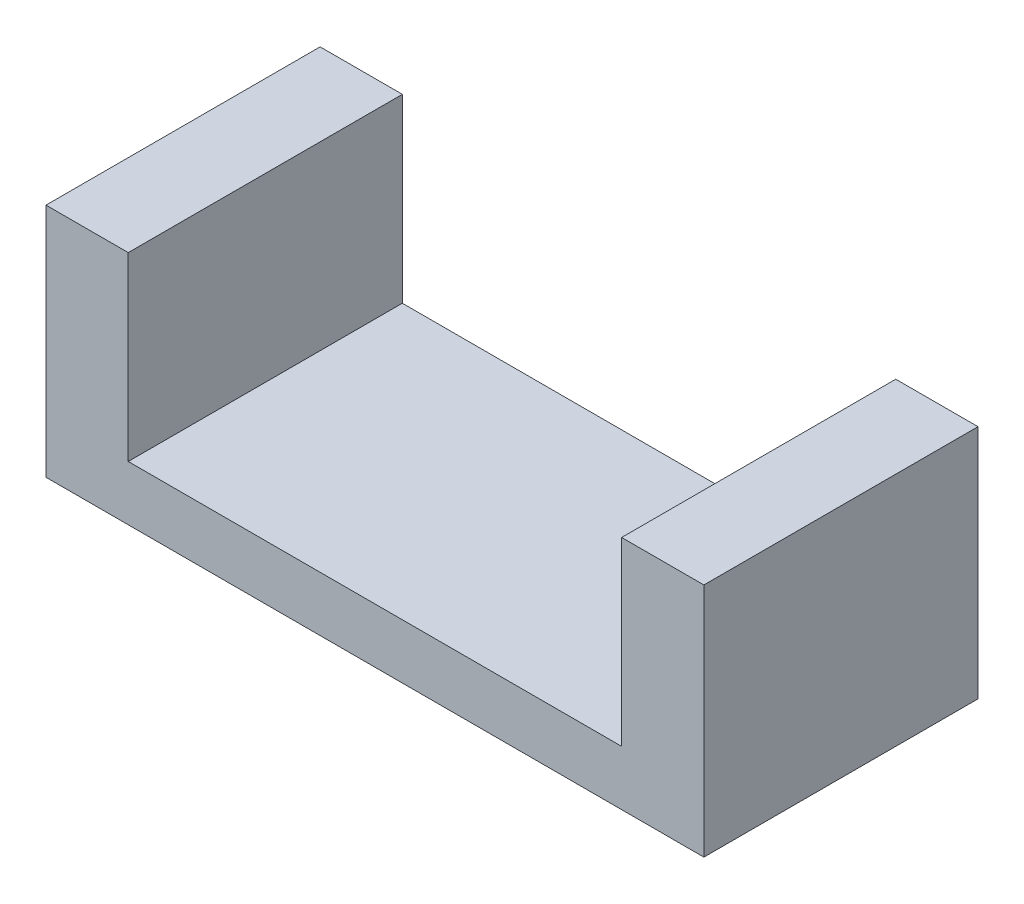
from build123d import *

# Parameters (mm, degrees)
SKETCH_1_W      = 9
SKETCH_1_H      = 5
EXTRUDE_1_DEPTH = 1
SKETCH_1_3_W    = 1.5
SKETCH_1_3_H    = 5
EXTRUDE_2_DEPTH = 4.3


with BuildPart() as part:
    # 草图1 → 凸台-拉伸1 (new body)
    with BuildSketch(Plane(origin=(0, 0, 0), x_dir=(1, 0, 0), z_dir=(0, 1, 0))):
        Rectangle(SKETCH_1_W, SKETCH_1_H)
    extrude(amount=EXTRUDE_1_DEPTH)

    # 草图1<3> → 凸台-拉伸2 (add)
    with BuildSketch(Plane(origin=(0, 0, 0), x_dir=(1, 0, 0), z_dir=(0, 1, 0))):
        with Locations((5.25, 0)):
            Rectangle(SKETCH_1_3_W, SKETCH_1_3_H)
        with Locations((-5.25, 0)):
            Rectangle(SKETCH_1_3_W, SKETCH_1_3_H)
    extrude(amount=EXTRUDE_2_DEPTH)


solid = part.part
